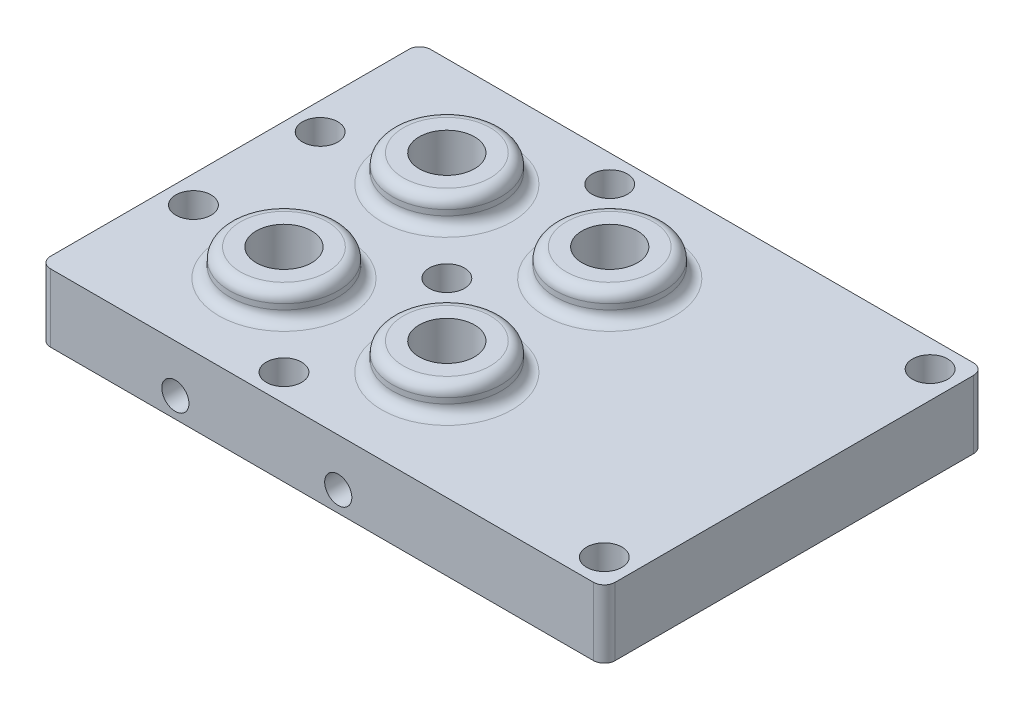
from build123d import *

# Parameters (mm, degrees)
SKETCH1_W                       = 104
SKETCH1_H                       = 70
BOSS_EXTRUDE1_DEPTH             = 5
SKETCH4_W                       = 104
SKETCH4_H                       = 70
SKETCH4_W_2                     = 94
SKETCH4_H_2                     = 60
BOSS_EXTRUDE3_DEPTH             = 7.5
SKETCH2_R                       = 10
BOSS_EXTRUDE2_DEPTH             = 5
BOSS_EXTRUDE2_DEPTH_BACK        = 12.5
SKETCH3_R                       = 5.1
CUT_EXTRUDE1_DEPTH              = 18.5
FILLET3_R                       = 2
SKETCH8_R                       = 5
BOSS_EXTRUDE5_DEPTH             = 12.5
CBORE_FOR_M3_SHCS2_D            = 3.4
CBORE_FOR_M3_SHCS2_CBORE_D      = 6.5
CBORE_FOR_M3_SHCS2_CBORE_DEPTH  = 8
FILLET4_R                       = 2
TAP_DRILL_FOR_M3X0_5_TAP3_D     = 2.5
TAP_DRILL_FOR_M3X0_5_TAP3_DEPTH = 20
TAP_DRILL_FOR_M3X0_5_TAP3_TIP   = 0.751075774
CUT_EXTRUDE2_REACH              = 72
SKETCH13_R                      = 2.5
TAP_DRILL_FOR_M3X0_5_TAP4_D     = 2.5
TAP_DRILL_FOR_M3X0_5_TAP4_DEPTH = 20
TAP_DRILL_FOR_M3X0_5_TAP4_TIP   = 0.751075774
CUT_EXTRUDE3_REACH              = 72
SKETCH18_R                      = 2.5


with BuildPart() as part:
    # Sketch1 → Boss-Extrude1 (new body)
    with BuildSketch(Plane(origin=(0, 0, 0), x_dir=(1, 0, 0), z_dir=(0, 1, 0))):
        with Locations((1.426420959, -6.527985064)):
            Rectangle(SKETCH1_W, SKETCH1_H)
    extrude(amount=BOSS_EXTRUDE1_DEPTH)

    # Sketch4 → Boss-Extrude3 (add)
    with BuildSketch(Plane.XZ):
        with Locations((1.426420959, 6.527985064)):
            Rectangle(SKETCH4_W, SKETCH4_H)
        with Locations((1.426420959, 6.527985064)):
            Rectangle(SKETCH4_W_2, SKETCH4_H_2, mode=Mode.SUBTRACT)
    extrude(amount=BOSS_EXTRUDE3_DEPTH)

    # Sketch2 → Boss-Extrude2 (add, two sides)
    with BuildSketch(Plane(origin=(0, 5, 0), x_dir=(-1, 0, 0), z_dir=(0, 1, 0))) as boss_extrude2_sk:
        with Locations(Location((25.573579041, -8.472014936, 0), (0, 0, 90))):  # turned: the seam where the file's is
            Circle(SKETCH2_R)
        with Locations(Location((25.573579041, 21.527985064, 0), (0, 0, 90))):  # turned: the seam where the file's is
            Circle(SKETCH2_R)
        with Locations(Location((-4.426420959, -8.472014936, 0), (0, 0, 90))):  # turned: the seam where the file's is
            Circle(SKETCH2_R)
        with Locations(Location((-4.426420959, 21.527985064, 0), (0, 0, 90))):  # turned: the seam where the file's is
            Circle(SKETCH2_R)
    extrude(amount=BOSS_EXTRUDE2_DEPTH)
    extrude(boss_extrude2_sk.sketch, amount=-BOSS_EXTRUDE2_DEPTH_BACK)

    # Sketch3 → Cut-Extrude1 (cut, through all)
    with BuildSketch(Plane(origin=(0, 10, 0), x_dir=(1, 0, 0), z_dir=(0, 1, 0))):
        with Locations(Location((-25.573579041, 8.472014936, 0), (0, 0, 270))):  # turned: the seam where the file's is
            Circle(SKETCH3_R)
        with Locations(Location((-25.573579041, -21.527985064, 0), (0, 0, 270))):  # turned: the seam where the file's is
            Circle(SKETCH3_R)
        with Locations(Location((4.426420959, -21.527985064, 0), (0, 0, 270))):  # turned: the seam where the file's is
            Circle(SKETCH3_R)
        with Locations(Location((4.426420959, 8.472014936, 0), (0, 0, 270))):  # turned: the seam where the file's is
            Circle(SKETCH3_R)
    extrude(amount=-CUT_EXTRUDE1_DEPTH, mode=Mode.SUBTRACT)

    # Fillet3
    fillet3_edges = [part.edges().sort_by_distance(p)[0] for p in [
        (-25.573579041, 5, -18.472014936),
        (-25.573579041, 10, -18.472014936),
        (-25.573579041, 5, 11.527985064),
        (-25.573579041, 10, 11.527985064),
        (4.426420959, 5, -18.472014936),
        (4.426420959, 10, -18.472014936),
        (4.426420959, 5, 11.527985064),
        (4.426420959, 10, 11.527985064),
    ]]
    fillet(fillet3_edges, radius=FILLET3_R)

    # Sketch8 → Boss-Extrude5 (add)
    with BuildSketch(Plane(origin=(0, 5, 0), x_dir=(1, 0, 0), z_dir=(0, 1, 0))):
        with Locations((-10.573579041, -36.527985064)):
            Circle(SKETCH8_R)
        with Locations((-45.573579041, -18.194651731)):
            Circle(SKETCH8_R)
        with Locations((-45.573579041, 5.138681602)):
            Circle(SKETCH8_R)
        with Locations(Location((-10.573579041, -6.527985064, 0), (0, 0, 270))):  # turned: the seam where the file's is
            Circle(SKETCH8_R)
        with Locations((-10.573579041, 23.472014936)):
            Circle(SKETCH8_R)
        with Locations((48.426420959, -36.527985064)):
            Circle(SKETCH8_R)
        with Locations((48.426420959, 23.472014936)):
            Circle(SKETCH8_R)
    extrude(amount=-BOSS_EXTRUDE5_DEPTH)

    # CBORE for M3 SHCS2 (through all)
    with Locations(Plane(origin=(-45.573579041, 5, -5.138681602), x_dir=(0, 0, 1), z_dir=(0, 1, 0))):
        with Locations((0, 0), (-18.333333334, 35), (11.666666666, 35), (23.333333333, 0), (41.666666666, 35), (41.666666666, 94), (-18.333333334, 94)):
            CounterBoreHole(CBORE_FOR_M3_SHCS2_D / 2, CBORE_FOR_M3_SHCS2_CBORE_D / 2, CBORE_FOR_M3_SHCS2_CBORE_DEPTH)

    # Fillet4
    fillet4_edges = [part.edges().sort_by_distance(p)[0] for p in [
        (-50.573579041, -1.25, -28.472014936),
        (53.426420959, -1.25, -28.472014936),
        (53.426420959, -1.25, 41.527985064),
        (-50.573579041, -1.25, 41.527985064),
    ]]
    fillet(fillet4_edges, radius=FILLET4_R)

    # Tap Drill for M3x0.5 Tap3
    with Locations(Plane(origin=(-25.573579041, -3.75, 41.527985064), x_dir=(1, 0, 0), z_dir=(0, 0, 1))):
        with Locations((0, 0), (30, 0)):
            Hole(TAP_DRILL_FOR_M3X0_5_TAP3_D / 2, depth=TAP_DRILL_FOR_M3X0_5_TAP3_DEPTH)
            with Locations((0, 0, -(TAP_DRILL_FOR_M3X0_5_TAP3_DEPTH + TAP_DRILL_FOR_M3X0_5_TAP3_TIP / 2))):  # 118° drill point
                Cone(0, TAP_DRILL_FOR_M3X0_5_TAP3_D / 2, TAP_DRILL_FOR_M3X0_5_TAP3_TIP, mode=Mode.SUBTRACT)

    # Sketch13 → Cut-Extrude2 (cut, up to next)
    with BuildSketch(Plane.XY.offset(41.527985064), mode=Mode.PRIVATE) as cut_extrude2_sk1:
        with Locations((-25.573579041, -3.75)):
            Circle(SKETCH13_R)
    cut_extrude2_tool1 = extrude(cut_extrude2_sk1.sketch, amount=-CUT_EXTRUDE2_REACH, mode=Mode.PRIVATE) & part.part
    add(cut_extrude2_tool1.solids().sort_by_distance((-25.573579, -3.75, 41.527985))[0], mode=Mode.SUBTRACT)
    # Sketch13 → Cut-Extrude2 (cut, up to next)
    with BuildSketch(Plane.XY.offset(41.527985064), mode=Mode.PRIVATE) as cut_extrude2_sk2:
        with Locations((4.426420959, -3.75)):
            Circle(SKETCH13_R)
    cut_extrude2_tool2 = extrude(cut_extrude2_sk2.sketch, amount=-CUT_EXTRUDE2_REACH, mode=Mode.PRIVATE) & part.part
    add(cut_extrude2_tool2.solids().sort_by_distance((4.426421, -3.75, 41.527985))[0], mode=Mode.SUBTRACT)

    # Tap Drill for M3x0.5 Tap4
    with Locations(Plane(origin=(0, 0, -28.472014936), x_dir=(-1, 0, 0), z_dir=(0, 0, -1))):
        with Locations((25.573579041, -3.75), (-4.426420959, -3.75)):
            Hole(TAP_DRILL_FOR_M3X0_5_TAP4_D / 2, depth=TAP_DRILL_FOR_M3X0_5_TAP4_DEPTH)
            with Locations((0, 0, -(TAP_DRILL_FOR_M3X0_5_TAP4_DEPTH + TAP_DRILL_FOR_M3X0_5_TAP4_TIP / 2))):  # 118° drill point
                Cone(0, TAP_DRILL_FOR_M3X0_5_TAP4_D / 2, TAP_DRILL_FOR_M3X0_5_TAP4_TIP, mode=Mode.SUBTRACT)

    # Sketch18 → Cut-Extrude3 (cut, up to next)
    with BuildSketch(Plane(origin=(0, 0, -28.472014936), x_dir=(-1, 0, 0), z_dir=(0, 0, -1)), mode=Mode.PRIVATE) as cut_extrude3_sk1:
        with Locations(Location((-4.426420959, -3.75, 0), (0, 0, 180))):  # turned: the seam where the file's is
            Circle(SKETCH18_R)
    cut_extrude3_tool1 = extrude(cut_extrude3_sk1.sketch, amount=-CUT_EXTRUDE3_REACH, mode=Mode.PRIVATE) & part.part
    add(cut_extrude3_tool1.solids().sort_by_distance((4.426421, -3.75, -28.472015))[0], mode=Mode.SUBTRACT)
    # Sketch18 → Cut-Extrude3 (cut, up to next)
    with BuildSketch(Plane(origin=(0, 0, -28.472014936), x_dir=(-1, 0, 0), z_dir=(0, 0, -1)), mode=Mode.PRIVATE) as cut_extrude3_sk2:
        with Locations(Location((25.573579041, -3.75, 0), (0, 0, 180))):  # turned: the seam where the file's is
            Circle(SKETCH18_R)
    cut_extrude3_tool2 = extrude(cut_extrude3_sk2.sketch, amount=-CUT_EXTRUDE3_REACH, mode=Mode.PRIVATE) & part.part
    add(cut_extrude3_tool2.solids().sort_by_distance((-25.573579, -3.75, -28.472015))[0], mode=Mode.SUBTRACT)


solid = part.part
